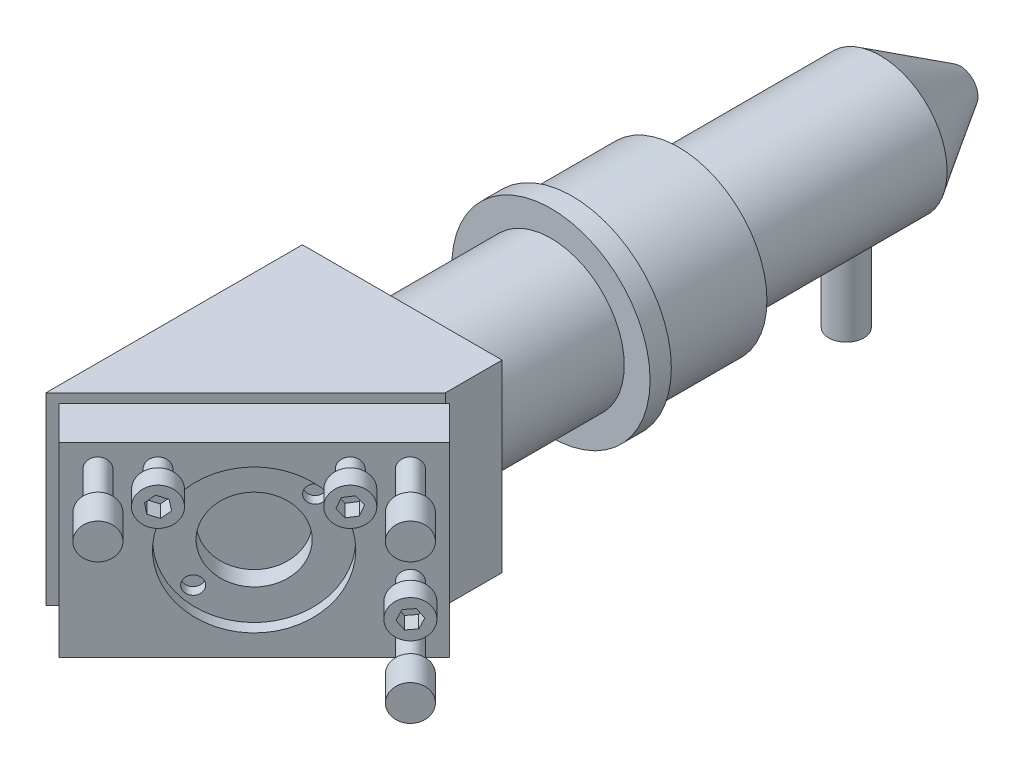
from build123d import *

# Parameters (mm, degrees)
SKETCH1_W                        = 28.2
SKETCH1_H                        = 26
BOSS_EXTRUDE1_DEPTH              = 60
CUT_EXTRUDE1_DEPTH               = 27
SKETCH3_R                        = 6
CUT_EXTRUDE2_DEPTH               = 60
SKETCH4_R                        = 1.5
CUT_EXTRUDE3_DEPTH               = 6
SKETCH5_R                        = 8.5
CUT_EXTRUDE4_DEPTH               = 29.2
SKETCH6_R                        = 11.7
CUT_EXTRUDE5_DEPTH               = 2.2
SKETCH7_R                        = 1.5
BOSS_EXTRUDE2_DEPTH              = 21.3
SKETCH8_R                        = 2.5
BOSS_EXTRUDE3_DEPTH              = 5
SKETCH9_W                        = 39
SKETCH9_H                        = 26.25
SKETCH9_R                        = 10.15
BOSS_EXTRUDE4_DEPTH              = 6.8
SKETCH11_R                       = 10
BOSS_EXTRUDE5_DEPTH              = 2
SKETCH12_R                       = 10.15
SKETCH12_R_2                     = 5.8
BOSS_EXTRUDE6_DEPTH              = 3
SKETCH20_R                       = 1.25
CUT_EXTRUDE7_DEPTH               = 1.5
SKETCH13_R                       = 1.5
BOSS_EXTRUDE7_DEPTH              = 3.5
BOSS_EXTRUDE7_DEPTH_BACK         = 11
SKETCH14_R                       = 2.65
BOSS_EXTRUDE8_DEPTH              = 0.5
SKETCH15_R                       = 2.65
BOSS_EXTRUDE9_DEPTH              = 2.5
SKETCH17_R                       = 9
LENS_DEPTH                       = 2
SKETCH18_R                       = 9
SKETCH18_R_2                     = 5.9
BOSS_EXTRUDE11_DEPTH             = 3
CHAMFER1_SIZE                    = 1
SKETCH19_R                       = 1
CUT_EXTRUDE6_DEPTH               = 1.5
SKETCH21_R                       = 2.5
BOSS_EXTRUDE12_DEPTH             = 12
BOSS_EXTRUDE12_DIRECTION_2_REACH = 25.44
SKETCH22_R                       = 1.25
CUT_EXTRUDE8_DEPTH               = 17


with BuildPart() as part:
    # Sketch1 → Boss-Extrude1 (new body)
    with BuildSketch(Plane.XY):
        Rectangle(SKETCH1_W, SKETCH1_H)
    extrude(amount=BOSS_EXTRUDE1_DEPTH)

    # Sketch2 → Cut-Extrude1 (cut, through all)
    with BuildSketch(Plane.XZ.offset(13)):
        Polygon((-14.1, 60), (-14.1, 36.2), (14.1, 8), (14.1, 60), align=None)
    extrude(amount=-CUT_EXTRUDE1_DEPTH, mode=Mode.SUBTRACT)

    # Sketch3 → Cut-Extrude2 (cut)
    with BuildSketch(Plane(origin=(0, 0, 0), x_dir=(-1, 0, 0), z_dir=(0, 0, -1))):
        Circle(SKETCH3_R)
    extrude(amount=-CUT_EXTRUDE2_DEPTH, mode=Mode.SUBTRACT)

    # Sketch4 → Cut-Extrude3 (cut)
    with BuildSketch(Plane(origin=(0, 0, 0), x_dir=(-1, 0, 0), z_dir=(0, 0, -1))):
        with Locations((9.75, -10)):
            Circle(SKETCH4_R)
        with Locations((-9.75, -10)):
            Circle(SKETCH4_R)
        with Locations((-9.75, 10)):
            Circle(SKETCH4_R)
        with Locations((9.75, 10)):
            Circle(SKETCH4_R)
    extrude(amount=-CUT_EXTRUDE3_DEPTH, mode=Mode.SUBTRACT)

    # Sketch5 → Cut-Extrude4 (cut, through all)
    with BuildSketch(Plane.ZY.offset(14.1)):
        with Locations((21.5, 0)):
            Circle(SKETCH5_R)
    extrude(amount=-CUT_EXTRUDE4_DEPTH, mode=Mode.SUBTRACT)

    # Sketch6 → Cut-Extrude5 (cut)
    with BuildSketch(Plane(origin=(11.05, 0, 11.05), x_dir=(0.707106781, 0, -0.707106781), z_dir=(0.707106781, 0, 0.707106781))):
        with Locations((-14.786648635, 0)):
            Circle(SKETCH6_R)
    extrude(amount=-CUT_EXTRUDE5_DEPTH, mode=Mode.SUBTRACT)

    # Sketch7 → Boss-Extrude2 (add)
    with BuildSketch(Plane(origin=(11.05, 0, 11.05), x_dir=(0.707106781, 0, -0.707106781), z_dir=(0.707106781, 0, 0.707106781))):
        with Locations((-30.386648635, 9.875)):
            Circle(SKETCH7_R)
        with Locations((0.813351365, 9.875)):
            Circle(SKETCH7_R)
        with Locations((0.813351365, -9.875)):
            Circle(SKETCH7_R)
    extrude(amount=BOSS_EXTRUDE2_DEPTH)

    # Sketch8 → Boss-Extrude3 (add)
    with BuildSketch(Plane(origin=(26.111374439, 0, 26.111374439), x_dir=(0.707106781, 0, -0.707106781), z_dir=(0.707106781, 0, 0.707106781))):
        with Locations((-30.386648635, 9.875)):
            Circle(SKETCH8_R)
        with Locations((0.813351365, 9.875)):
            Circle(SKETCH8_R)
        with Locations((0.813351365, -9.875)):
            Circle(SKETCH8_R)
    extrude(amount=-BOSS_EXTRUDE3_DEPTH)

    # Sketch9 → Boss-Extrude4 (add)
    with BuildSketch(Plane(origin=(12.464213562, 0, 12.464213562), x_dir=(0.707106781, 0, -0.707106781), z_dir=(0.707106781, 0, 0.707106781))):
        with Locations((-14.786648635, 0)):
            Rectangle(SKETCH9_W, SKETCH9_H)
        with Locations((-14.786648635, 0)):
            Circle(SKETCH9_R, mode=Mode.SUBTRACT)
    extrude(amount=BOSS_EXTRUDE4_DEPTH)

    # Sketch10 → Revolve1 (revolve)
    with BuildSketch(Plane(origin=(0, 0, 0), x_dir=(1, 0, 0), z_dir=(0, 1, 0))):
        Polygon((-5.168659787, -30.097086912), (-5.769700551, -30.698127676), (-5.769700551, -29.283914114), (-5.154517652, -28.668731214), (-4.447410871, -28.668731214), (-4.09385748, -29.022284605), align=None)
    revolve(axis=Axis((5.1205952, 0, 26.032074241), (0.707106781, 0, 0.707106781)))

    # Sketch11 → Boss-Extrude5 (add)
    with BuildSketch(Plane(origin=(12.464213562, 0, 12.464213562), x_dir=(0.707106781, 0, -0.707106781), z_dir=(0.707106781, 0, 0.707106781))):
        with Locations((-14.786648635, 0)):
            Circle(SKETCH11_R)
    extrude(amount=BOSS_EXTRUDE5_DEPTH)

    # Sketch12 → Boss-Extrude6 (add)
    with BuildSketch(Plane(origin=(13.878427125, 0, 13.878427125), x_dir=(0.707106781, 0, -0.707106781), z_dir=(0.707106781, 0, 0.707106781))):
        with Locations((-14.786648635, 0)):
            Circle(SKETCH12_R)
        with Locations((-14.786648635, 0)):
            Circle(SKETCH12_R_2, mode=Mode.SUBTRACT)
    extrude(amount=BOSS_EXTRUDE6_DEPTH)

    # Sketch20 → Cut-Extrude7 (cut)
    with BuildSketch(Plane(origin=(15.999747468, 0, 15.999747468), x_dir=(0.707106781, 0, -0.707106781), z_dir=(0.707106781, 0, 0.707106781))):
        with Locations((-20.873794517, -5.568586446)):
            Circle(SKETCH20_R)
        with Locations((-8.699502752, 5.568586446)):
            Circle(SKETCH20_R)
    extrude(amount=-CUT_EXTRUDE7_DEPTH, mode=Mode.SUBTRACT)

    # Sketch13 → Boss-Extrude7 (add, two sides)
    with BuildSketch(Plane(origin=(17.272539674, 0, 17.272539674), x_dir=(0.707106781, 0, -0.707106781), z_dir=(0.707106781, 0, 0.707106781))) as boss_extrude7_sk:
        with Locations((-24.386648635, 9.875)):
            Circle(SKETCH13_R)
        with Locations((-5.186648635, 9.875)):
            Circle(SKETCH13_R)
        with Locations((0.813351365, -3.875)):
            Circle(SKETCH13_R)
    extrude(amount=BOSS_EXTRUDE7_DEPTH)
    extrude(boss_extrude7_sk.sketch, amount=-BOSS_EXTRUDE7_DEPTH_BACK)

    # Sketch14 → Boss-Extrude8 (add)
    with BuildSketch(Plane(origin=(19.747413409, 0, 19.747413409), x_dir=(0.707106781, 0, -0.707106781), z_dir=(0.707106781, 0, 0.707106781))):
        with Locations((0.813351365, -3.875)):
            Circle(SKETCH14_R)
        with Locations((-5.186648635, 9.875)):
            Circle(SKETCH14_R)
        with Locations((-24.386648635, 9.875)):
            Circle(SKETCH14_R)
    extrude(amount=BOSS_EXTRUDE8_DEPTH)

    # Sketch15 → Boss-Extrude9 (add)
    with BuildSketch(Plane(origin=(20.100966799, 0, 20.100966799), x_dir=(0.707106781, 0, -0.707106781), z_dir=(0.707106781, 0, 0.707106781))):
        with Locations((0.813351365, -3.875)):
            Circle(SKETCH15_R)
        Polygon((1.646417669, -5.053700075), (2.250668726, -3.742893455), (1.417602422, -2.56419338), (-0.019714939, -2.696299925), (-0.623965995, -4.007106545), (0.209100309, -5.18580662), align=None, mode=Mode.SUBTRACT)
        with Locations((-5.186648635, 9.875)):
            Circle(SKETCH15_R)
        Polygon((-3.760518363, 10.097453997), (-4.666234312, 11.221292043), (-6.092364583, 10.998838046), (-6.612778907, 9.652546003), (-5.707062958, 8.528707957), (-4.280932686, 8.751161954), align=None, mode=Mode.SUBTRACT)
        with Locations((-24.386648635, 9.875)):
            Circle(SKETCH15_R)
        Polygon((-23.273760703, 10.794137522), (-24.626201112, 11.298357982), (-25.739089044, 10.37922046), (-25.499536567, 8.955862478), (-24.147096157, 8.451642018), (-23.034208225, 9.37077954), align=None, mode=Mode.SUBTRACT)
    extrude(amount=BOSS_EXTRUDE9_DEPTH)

    # Sketch16 → Revolve2 (revolve)
    with BuildSketch(Plane(origin=(0, 0, 0), x_dir=(1, 0, 0), z_dir=(0, 1, 0))):
        Polygon((8, 0), (10.35, 0), (10.35, 21), (14, 21), (14, 24), (12.5, 24), (12.5, 39), (9.44, 39), (9.44, 67.5), (2.5, 78.8), (2.1, 78.8), (6.65, 67.5), (6.65, 37), (9, 37), (9, 30.4), (8, 30.4), align=None)
    revolve(axis=Axis((0, 0, 0), (0, 0, -1)))

    # Sketch17 → lens (add)
    with BuildSketch(Plane.XY.offset(-37)):
        Circle(SKETCH17_R)
    extrude(amount=LENS_DEPTH)

    # Sketch18 → Boss-Extrude11 (add)
    with BuildSketch(Plane.XY.offset(-35)):
        Circle(SKETCH18_R)
        Circle(SKETCH18_R_2, mode=Mode.SUBTRACT)
    extrude(amount=BOSS_EXTRUDE11_DEPTH)

    # Chamfer1
    chamfer1_edges = [part.edges().sort_by_distance(p)[0] for p in [
        (-5.9, 0, -32),
    ]]
    chamfer(chamfer1_edges, length=CHAMFER1_SIZE)

    # Sketch19 → Cut-Extrude6 (cut)
    with BuildSketch(Plane.XY.offset(-32)):
        with Locations((-5.533504006, 5.062640952)):
            Circle(SKETCH19_R)
        with Locations((5.533504006, -5.062640952)):
            Circle(SKETCH19_R)
    extrude(amount=-CUT_EXTRUDE6_DEPTH, mode=Mode.SUBTRACT)


with BuildPart() as body_2:
    # Sketch21 → Boss-Extrude12 (new body)
    with BuildSketch(Plane(origin=(0, -9.44, 0), x_dir=(-1, 0, 0), z_dir=(0, -1, 0))):
        with Locations((0, 62.7)):
            Circle(SKETCH21_R)
    extrude(amount=BOSS_EXTRUDE12_DEPTH)


    # Sketch21 → Boss-Extrude12 direction 2 (add, up to next)
    with BuildSketch(Plane(origin=(0, -9.44, 0), x_dir=(-1, 0, 0), z_dir=(0, -1, 0)), mode=Mode.PRIVATE) as boss_extrude12_direction_2_sk1:
        with Locations((0, 62.7)):
            Circle(SKETCH21_R)
    boss_extrude12_direction_2_tool1 = extrude(boss_extrude12_direction_2_sk1.sketch, amount=-BOSS_EXTRUDE12_DIRECTION_2_REACH, mode=Mode.PRIVATE) - part.part
    add(boss_extrude12_direction_2_tool1.solids().sort_by_distance((0, -9.44, -62.7))[0])
    add(boss_extrude12_direction_2_tool1.solids().sort_by_distance((0, -9.44, -62.7))[1])


with BuildPart() as cut_extrude8_tool:
    # Sketch22 → Cut-Extrude8 (new body)
    with BuildSketch(Plane.XZ.offset(21.44)):
        with Locations((0, -62.7)):
            Circle(SKETCH22_R)
    extrude(amount=-CUT_EXTRUDE8_DEPTH)


with BuildPart() as part_1:
    add(part.part)

    # Cut-Extrude8: cut by cut_extrude8_tool
    add(cut_extrude8_tool.part, mode=Mode.SUBTRACT)


with BuildPart() as body_2_1:
    add(body_2.part)

    # Cut-Extrude8: cut by cut_extrude8_tool
    add(cut_extrude8_tool.part, mode=Mode.SUBTRACT)


solid = Compound([part_1.part, body_2_1.part])
